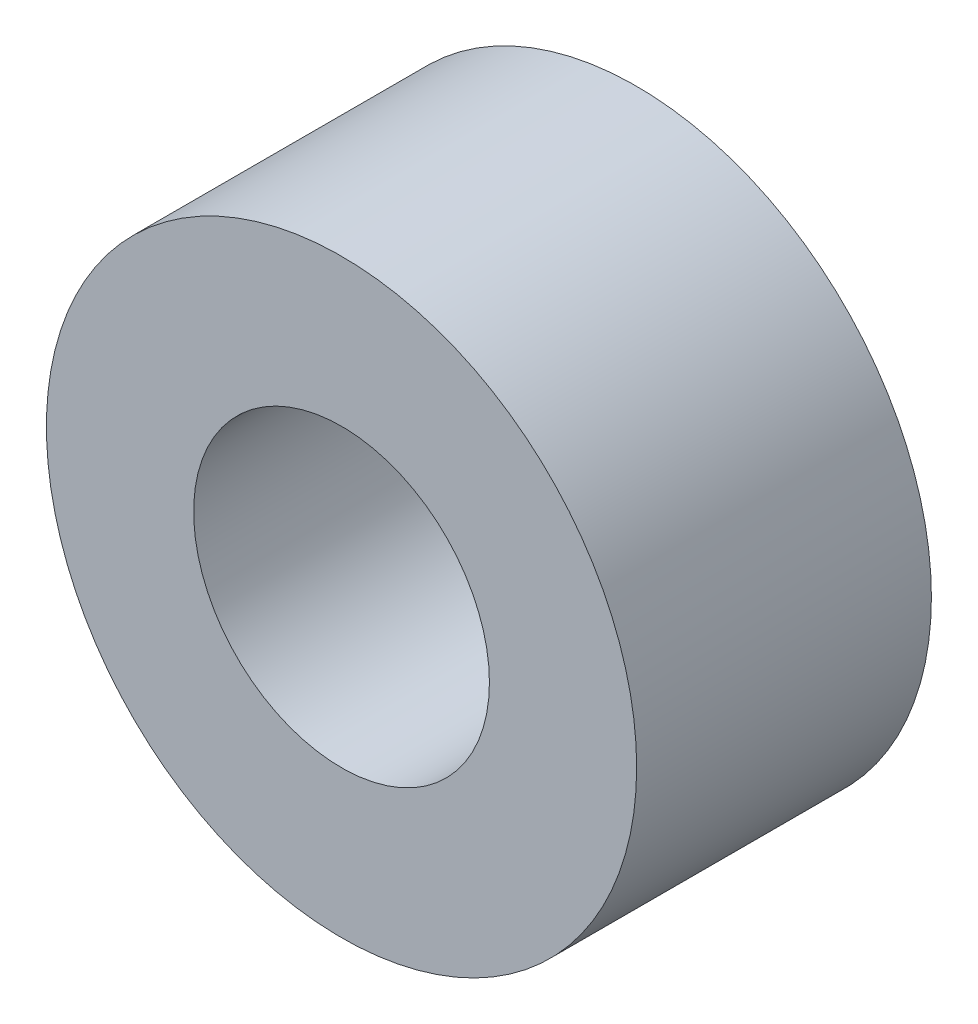
from build123d import *

# Parameters (mm, degrees)
SKETCH1_R          = 60.078040142
EXTRUDE1_DEPTH     = 60
SKETCH2_R          = 30.106009883
CUT_EXTRUDE1_DEPTH = 60


with BuildPart() as part:
    # Sketch1 → Extrude1 (new body)
    with BuildSketch(Plane.XY):
        Circle(SKETCH1_R)
    extrude(amount=EXTRUDE1_DEPTH)

    # Sketch2 → Cut-Extrude1 (cut)
    with BuildSketch(Plane.XY.offset(60)):
        Circle(SKETCH2_R)
    extrude(amount=-CUT_EXTRUDE1_DEPTH, mode=Mode.SUBTRACT)


solid = part.part
